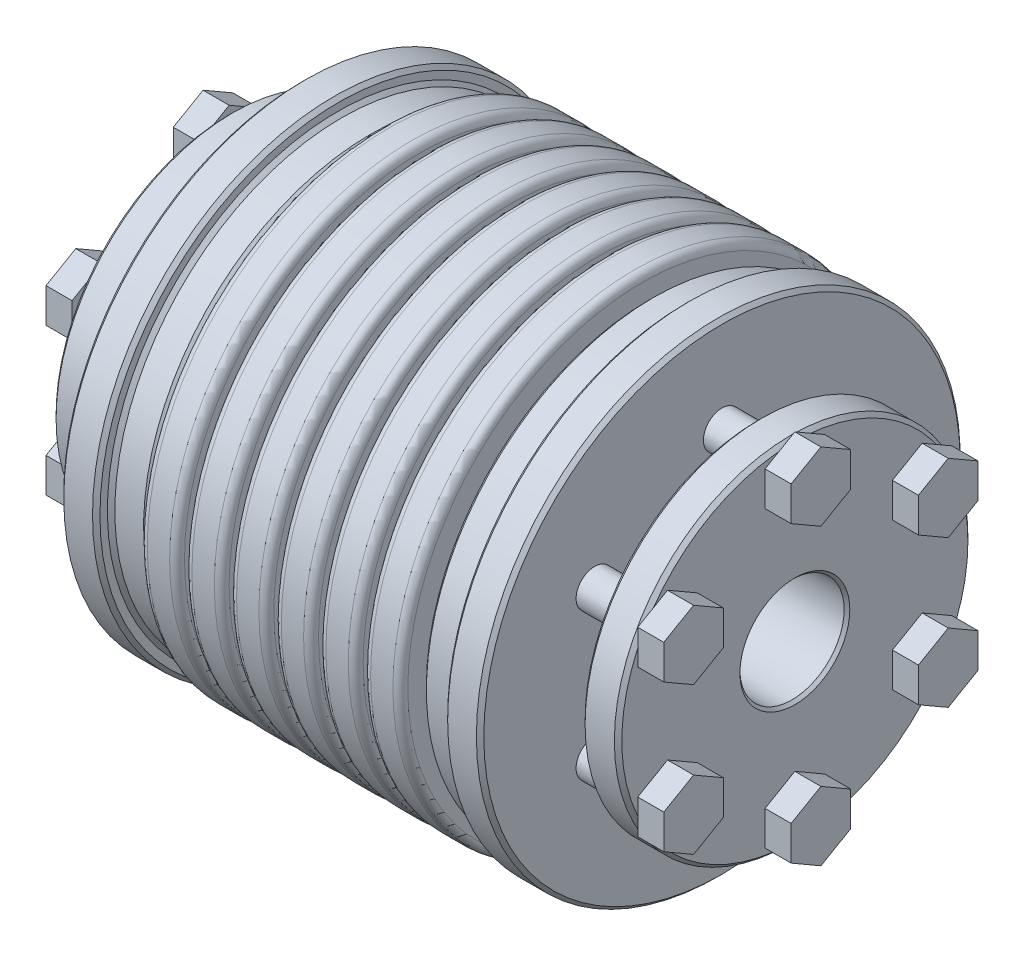
from build123d import *

# Parameters (mm, degrees)
SKETCH1_R                      = 32.5
BOSS_EXTRUDE1_DEPTH            = 38
SKETCH2_R                      = 7
CUT_EXTRUDE1_DEPTH             = 19
CHAMFER1_SIZE                  = 0.381
CUT_EXTRUDE2_REACH             = 40
SKETCH5_R                      = 19.9405
CUT_EXTRUDE2_DIRECTION_2_REACH = 40
SKETCH8_W                      = 1
SKETCH8_H                      = 10.5595
FILLET1_R                      = 1
FILLET2_R                      = 0.25
BOSS_EXTRUDE2_DEPTH            = 3.5
BOSS_EXTRUDE2_2_DEPTH          = 3.5
BOSS_EXTRUDE2_3_DEPTH          = 3.5
BOSS_EXTRUDE2_4_DEPTH          = 3.5
BOSS_EXTRUDE2_5_DEPTH          = 3.5
BOSS_EXTRUDE2_6_DEPTH          = 3.5
SKETCH11_R                     = 2.5
BOSS_EXTRUDE3_DEPTH            = 13.287458
CHAMFER2_SIZE                  = 0.5


with BuildPart() as part:
    # Sketch1 → Boss-Extrude1 (new body, symmetric)
    with BuildSketch(Plane(origin=(0, 0, 0), x_dir=(0, 0, -1), z_dir=(1, 0, 0))):
        Circle(SKETCH1_R)
    extrude(amount=BOSS_EXTRUDE1_DEPTH, both=True)

    # Sketch2 → Cut-Extrude1 (cut)
    with BuildSketch(Plane(origin=(38, 0, 0), x_dir=(0, 0, -1), z_dir=(1, 0, 0))):
        Circle(SKETCH2_R)
    cut_extrude1 = extrude(amount=-CUT_EXTRUDE1_DEPTH, mode=Mode.SUBTRACT)

    # Mirror3: Cut-Extrude1 across plane
    add(cut_extrude1.mirror(Plane(origin=(0, 0, 0), x_dir=(0, 0, 1), z_dir=(1, 0, 0))), mode=Mode.SUBTRACT)

    # Chamfer1
    chamfer1_edges = [part.edges().sort_by_distance(p)[0] for p in [
        (-38, 0, 32.5),
        (38, 0, 32.5),
        (38, 0, 7),
        (-38, 0, 7),
    ]]
    chamfer(chamfer1_edges, length=CHAMFER1_SIZE)

    # Cut-Extrude2: up to this face of the body (flat: up to its plane)
    cut_extrude2_end = Plane(part.part.faces().sort_by_distance((-19, 0, 0))[0])
    # Sketch5 → Cut-Extrude2 (cut, up to the picked face)
    with BuildSketch(Plane(origin=(0, 0, 0), x_dir=(0, 0, -1), z_dir=(1, 0, 0)), mode=Mode.PRIVATE) as cut_extrude2_sk1:
        Circle(SKETCH5_R)
    cut_extrude2_tool1 = split(extrude(cut_extrude2_sk1.sketch, amount=-CUT_EXTRUDE2_REACH, mode=Mode.PRIVATE), bisect_by=cut_extrude2_end, keep=Keep.BOTH, mode=Mode.PRIVATE)
    add(cut_extrude2_tool1.solids().sort_by(Axis((0, 0, 0), (-1, 0, 0)))[0], mode=Mode.SUBTRACT)

    # Cut-Extrude2 direction 2: up to this face of the body (flat: up to its plane)
    cut_extrude2_direction_2_end = Plane(part.part.faces().sort_by_distance((19, 0, 0))[0])
    # Sketch5 → Cut-Extrude2 direction 2 (cut, up to the picked face)
    with BuildSketch(Plane(origin=(0, 0, 0), x_dir=(0, 0, -1), z_dir=(1, 0, 0)), mode=Mode.PRIVATE) as cut_extrude2_direction_2_sk1:
        Circle(SKETCH5_R)
    cut_extrude2_direction_2_tool1 = split(extrude(cut_extrude2_direction_2_sk1.sketch, amount=CUT_EXTRUDE2_DIRECTION_2_REACH, mode=Mode.PRIVATE), bisect_by=cut_extrude2_direction_2_end, keep=Keep.BOTH, mode=Mode.PRIVATE)
    add(cut_extrude2_direction_2_tool1.solids().sort_by(Axis((0, 0, 0), (1, 0, 0)))[0], mode=Mode.SUBTRACT)

    # Sketch8 → Cut-Revolve1 (revolve, cut)
    with BuildSketch(Plane(origin=(0, 0, 0), x_dir=(1, 0, 0), z_dir=(0, 1, 0)), mode=Mode.PRIVATE) as cut_revolve1_sk:
        with Locations((0, 27.22025)):
            Rectangle(SKETCH8_W, SKETCH8_H)
        with Locations((6, 27.22025)):
            Rectangle(SKETCH8_W, SKETCH8_H)
        with Locations((12, 27.22025)):
            Rectangle(SKETCH8_W, SKETCH8_H)
        with Locations((18, 27.22025)):
            Rectangle(SKETCH8_W, SKETCH8_H)
    cut_revolve1 = revolve(cut_revolve1_sk.sketch.rotate(Axis((0, 0, 0), (1, 0, 0)), 180), axis=Axis((0, 0, 0), (1, 0, 0)), mode=Mode.SUBTRACT)  # turned: the seam where the file's is

    # Mirror2: Cut-Revolve1 across plane
    add(cut_revolve1.mirror(Plane(origin=(0, 0, 0), x_dir=(0, 0, 1), z_dir=(1, 0, 0))), mode=Mode.SUBTRACT)

    # Fillet1
    fillet1_edges = [part.edges().sort_by_distance(p)[0] for p in [
        (-0.5, 0, 32.5),
        (0.5, 0, 32.5),
        (17.5, 0, 32.5),
        (18.5, 0, 32.5),
        (5.5, 0, 32.5),
        (6.5, 0, 32.5),
        (11.5, 0, 32.5),
        (12.5, 0, 32.5),
        (-18.5, 0, 32.5),
        (-17.5, 0, 32.5),
        (-5.5, 0, 32.5),
        (-6.5, 0, 32.5),
        (-11.5, 0, 32.5),
        (-12.5, 0, 32.5),
    ]]
    fillet(fillet1_edges, radius=FILLET1_R)

    # Fillet2
    fillet2_edges = [part.edges().sort_by_distance(p)[0] for p in [
        (0.5, 0, -21.9405),
        (-0.5, 0, -21.9405),
        (18.5, 0, -21.9405),
        (17.5, 0, -21.9405),
        (6.5, 0, -21.9405),
        (5.5, 0, -21.9405),
        (12.5, 0, -21.9405),
        (11.5, 0, -21.9405),
        (-18.5, 0, -21.9405),
        (-17.5, 0, -21.9405),
        (-5.5, 0, -21.9405),
        (-6.5, 0, -21.9405),
        (-11.5, 0, -21.9405),
        (-12.5, 0, -21.9405),
    ]]
    fillet(fillet2_edges, radius=FILLET2_R)

    # Sketch9 → Cut-Revolve2 (revolve, cut)
    with BuildSketch(Plane.XY, mode=Mode.PRIVATE) as cut_revolve2_sk:
        Polygon((18.5, 30.5), (23.356271048, 30.5), (23.356271048, 32.5), (28.212542096, 32.5), (28.212542096, 14.893708389), (33.068813143, 15.75), (33.068813143, 23.75), (38, 23.75), (38, 37.5), (18.5, 37.5), align=None)
        Polygon((-18.5, 37.5), (-18.5, 30.5), (-23.356271048, 30.5), (-23.356271048, 32.5), (-28.212542096, 32.5), (-28.212542096, 14.893708389), (-33.068813143, 15.75), (-33.068813143, 23.75), (-38, 23.75), (-38, 37.5), align=None)
    revolve(cut_revolve2_sk.sketch.rotate(Axis((38, 0, 0), (-1, 0, 0)), 270), axis=Axis((38, 0, 0), (-1, 0, 0)), mode=Mode.SUBTRACT)  # turned: the seam where the file's is

    # Chamfer2
    chamfer2_edges = [part.edges().sort_by_distance(p)[0] for p in [
        (18.5, 0, -30.5),
        (23.356271048, 0, -30.5),
        (23.356271048, 0, 32.5),
        (28.212542096, 0, 32.5),
        (33.068813143, 0, -23.75),
        (38, 0, -23.75),
        (-33.068813143, 0, -23.75),
        (-38, 0, -23.75),
        (-18.5, 0, -30.5),
        (-23.356271048, 0, -30.5),
        (-23.356271048, 0, 32.5),
        (-28.212542096, 0, 32.5),
    ]]
    chamfer(chamfer2_edges, length=CHAMFER2_SIZE)


with BuildPart() as body_2:
    # Sketch10 → Boss-Extrude2 (new body)
    with BuildSketch(Plane(origin=(38, 0, 0), x_dir=(0, 0, -1), z_dir=(1, 0, 0))):
        Polygon((13.104001725, 7.565598923), (17.104001725, 5.256197846), (21.104001725, 7.565598923), (21.104001725, 12.184401077), (17.104001725, 14.493802154), (13.104001725, 12.184401077), align=None)
    extrude(amount=BOSS_EXTRUDE2_DEPTH)


with BuildPart() as body_3:
    # Sketch10 → Boss-Extrude2 2 (new body)
    with BuildSketch(Plane(origin=(38, 0, 0), x_dir=(0, 0, -1), z_dir=(1, 0, 0))):
        Polygon((0, 15.131197846), (4, 17.440598923), (4, 22.059401077), (0, 24.368802154), (-4, 22.059401077), (-4, 17.440598923), align=None)
    extrude(amount=BOSS_EXTRUDE2_2_DEPTH)


    add(body_2.part)  # Boss-Extrude3 merges body 2


with BuildPart() as body_4:
    # Sketch10 → Boss-Extrude2 3 (new body)
    with BuildSketch(Plane(origin=(38, 0, 0), x_dir=(0, 0, -1), z_dir=(1, 0, 0))):
        Polygon((13.104001725, -7.565598923), (13.104001725, -12.184401077), (17.104001725, -14.493802154), (21.104001725, -12.184401077), (21.104001725, -7.565598923), (17.104001725, -5.256197846), align=None)
    extrude(amount=BOSS_EXTRUDE2_3_DEPTH)


with BuildPart() as body_5:
    # Sketch10 → Boss-Extrude2 4 (new body)
    with BuildSketch(Plane(origin=(38, 0, 0), x_dir=(0, 0, -1), z_dir=(1, 0, 0))):
        Polygon((0, -15.131197846), (-4, -17.440598923), (-4, -22.059401077), (0, -24.368802154), (4, -22.059401077), (4, -17.440598923), align=None)
    extrude(amount=BOSS_EXTRUDE2_4_DEPTH)


with BuildPart() as body_6:
    # Sketch10 → Boss-Extrude2 5 (new body)
    with BuildSketch(Plane(origin=(38, 0, 0), x_dir=(0, 0, -1), z_dir=(1, 0, 0))):
        Polygon((-13.104001725, -7.565598923), (-17.104001725, -5.256197846), (-21.104001725, -7.565598923), (-21.104001725, -12.184401077), (-17.104001725, -14.493802154), (-13.104001725, -12.184401077), align=None)
    extrude(amount=BOSS_EXTRUDE2_5_DEPTH)


with BuildPart() as body_7:
    # Sketch10 → Boss-Extrude2 6 (new body)
    with BuildSketch(Plane(origin=(38, 0, 0), x_dir=(0, 0, -1), z_dir=(1, 0, 0))):
        Polygon((-13.104001725, 7.565598923), (-13.104001725, 12.184401077), (-17.104001725, 14.493802154), (-21.104001725, 12.184401077), (-21.104001725, 7.565598923), (-17.104001725, 5.256197846), align=None)
    extrude(amount=BOSS_EXTRUDE2_6_DEPTH)


with BuildPart() as body_3_1:
    add(body_3.part)

    add(body_4.part)  # Boss-Extrude3 merges body 4

    add(body_5.part)  # Boss-Extrude3 merges body 5

    add(body_6.part)  # Boss-Extrude3 merges body 6

    add(body_7.part)  # Boss-Extrude3 merges body 7
    # Sketch11 → Boss-Extrude3 (add)
    with BuildSketch(Plane(origin=(41.5, 0, 0), x_dir=(0, 0, -1), z_dir=(1, 0, 0))):
        with Locations((0, 19.75)):
            Circle(SKETCH11_R)
        with Locations((17.104001725, 9.875)):
            Circle(SKETCH11_R)
        with Locations((17.104001725, -9.875)):
            Circle(SKETCH11_R)
        with Locations((0, -19.75)):
            Circle(SKETCH11_R)
        with Locations((-17.104001725, -9.875)):
            Circle(SKETCH11_R)
        with Locations((-17.104001725, 9.875)):
            Circle(SKETCH11_R)
    extrude(amount=-BOSS_EXTRUDE3_DEPTH)


with BuildPart() as body_3_2:
    # Mirror5: mirrored copy
    add(body_3_1.part.mirror(Plane(origin=(0, 0, 0), x_dir=(0, 0, 1), z_dir=(1, 0, 0))))


solid = Compound([part.part, body_3_1.part, body_3_2.part])
